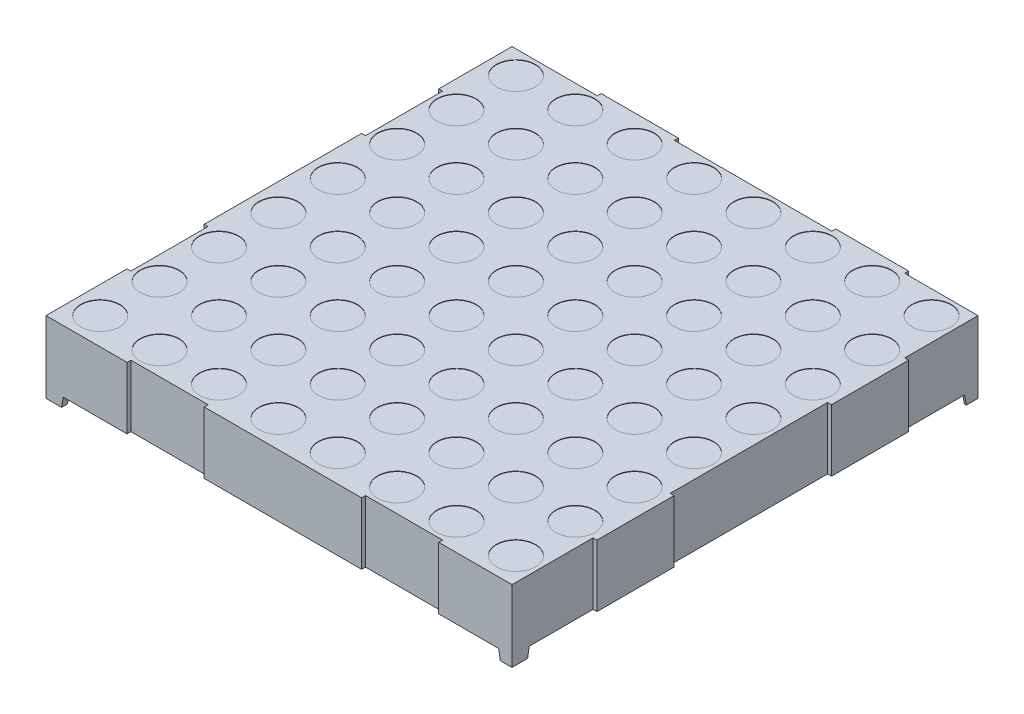
from build123d import *
from build123d.topology import SkipClean

# Parameters (mm, degrees)
EXTRUDE1_DEPTH     = 30.15
CUT_EXTRUDE1_DEPTH = 61.3
SKETCH2_R          = 2.5
CUT_EXTRUDE2_DEPTH = 0.05
SKETCH4_R          = 0.25
EXTRUDE2_DEPTH     = 1.25
SKETCH4_3_R        = 0.25
EXTRUDE3_DEPTH     = 4
SKETCH4_4_W        = 1.470408726
SKETCH4_4_H        = 1.470408726
CUT_EXTRUDE3_DEPTH = 1.25
SKETCH2_4_W        = 0.5
SKETCH2_4_H        = 9.9
SKETCH2_4_H_2      = 10.4
SKETCH2_4_H_3      = 20.2
SKETCH2_4_W_2      = 10.94
SKETCH2_4_H_4      = 0.5
SKETCH2_4_W_3      = 20.2
SKETCH2_4_W_4      = 9.4
SKETCH2_4_W_5      = 9.9
CUT_EXTRUDE5_DEPTH = 14.2
SKETCH5_W          = 0.026582279
SKETCH5_H          = 0.025316455
CUT_EXTRUDE6_DEPTH = 0.01


with BuildPart() as part:
    # Sketch1 → Extrude1 (new body, symmetric)
    with BuildSketch(Plane(origin=(0, 0, 0), x_dir=(0, 0, -1), z_dir=(1, 0, 0))):
        Polygon((30.15, 4.6), (-30.15, 4.6), (21.957065217, -3.35), (27.929591274, -3.35), (28.094707932, -4.286423101), (30.15, -4.6), align=None)
        Polygon((21.957065217, -3.35), (-30.15, 4.6), (-30.15, -4.6), (-28.15, -4.6), (-27.929591274, -3.35), align=None)
        Polygon((30.15, -4.6), (28.094707932, -4.286423101), (28.15, -4.6), align=None)
    extrude(amount=EXTRUDE1_DEPTH, both=True)

    # Sketch3 → Cut-Extrude1 (cut, through all)
    with BuildSketch(Plane.XY.offset(30.15)):
        Polygon((-27.929591274, -3.35), (-28.15, -4.6), (28.15, -4.6), (27.929591274, -3.35), align=None)
    extrude(amount=-CUT_EXTRUDE1_DEPTH, mode=Mode.SUBTRACT)

    # Sketch2 → Cut-Extrude2 (cut)
    with BuildSketch(Plane(origin=(0, 4.6, 0), x_dir=(-1, 0, 0), z_dir=(0, 1, 0))):
        with Locations(Location((11.43, 19.05, 0), (0, 0, 270))):  # turned: the seam where the file's is
            Circle(SKETCH2_R)
        with Locations(Location((11.43, -11.43, 0), (0, 0, 270))):  # turned: the seam where the file's is
            Circle(SKETCH2_R)
        with Locations(Location((11.43, -3.81, 0), (0, 0, 270))):  # turned: the seam where the file's is
            Circle(SKETCH2_R)
        with Locations(Location((11.43, -19.05, 0), (0, 0, 270))):  # turned: the seam where the file's is
            Circle(SKETCH2_R)
        with Locations(Location((11.43, 3.81, 0), (0, 0, 270))):  # turned: the seam where the file's is
            Circle(SKETCH2_R)
        with Locations(Location((11.43, 26.67, 0), (0, 0, 270))):  # turned: the seam where the file's is
            Circle(SKETCH2_R)
        with Locations(Location((11.43, 11.43, 0), (0, 0, 270))):  # turned: the seam where the file's is
            Circle(SKETCH2_R)
        with Locations(Location((3.81, -3.81, 0), (0, 0, 270))):  # turned: the seam where the file's is
            Circle(SKETCH2_R)
        with Locations(Location((3.81, 3.81, 0), (0, 0, 270))):  # turned: the seam where the file's is
            Circle(SKETCH2_R)
        with Locations(Location((3.81, 19.05, 0), (0, 0, 270))):  # turned: the seam where the file's is
            Circle(SKETCH2_R)
        with Locations(Location((3.81, 26.67, 0), (0, 0, 270))):  # turned: the seam where the file's is
            Circle(SKETCH2_R)
        with Locations(Location((3.81, -11.43, 0), (0, 0, 270))):  # turned: the seam where the file's is
            Circle(SKETCH2_R)
        with Locations(Location((3.81, -19.05, 0), (0, 0, 270))):  # turned: the seam where the file's is
            Circle(SKETCH2_R)
        with Locations(Location((3.81, 11.43, 0), (0, 0, 270))):  # turned: the seam where the file's is
            Circle(SKETCH2_R)
        with Locations(Location((-3.81, -3.81, 0), (0, 0, 270))):  # turned: the seam where the file's is
            Circle(SKETCH2_R)
        with Locations(Location((-3.81, 3.81, 0), (0, 0, 270))):  # turned: the seam where the file's is
            Circle(SKETCH2_R)
        with Locations(Location((-3.81, 19.05, 0), (0, 0, 270))):  # turned: the seam where the file's is
            Circle(SKETCH2_R)
        with Locations(Location((-3.81, 26.67, 0), (0, 0, 270))):  # turned: the seam where the file's is
            Circle(SKETCH2_R)
        with Locations(Location((-3.81, -11.43, 0), (0, 0, 270))):  # turned: the seam where the file's is
            Circle(SKETCH2_R)
        with Locations(Location((-3.81, -19.05, 0), (0, 0, 270))):  # turned: the seam where the file's is
            Circle(SKETCH2_R)
        with Locations(Location((-3.81, 11.43, 0), (0, 0, 270))):  # turned: the seam where the file's is
            Circle(SKETCH2_R)
        with Locations(Location((19.05, -3.81, 0), (0, 0, 270))):  # turned: the seam where the file's is
            Circle(SKETCH2_R)
        with Locations(Location((19.05, 3.81, 0), (0, 0, 270))):  # turned: the seam where the file's is
            Circle(SKETCH2_R)
        with Locations(Location((19.05, 19.05, 0), (0, 0, 270))):  # turned: the seam where the file's is
            Circle(SKETCH2_R)
        with Locations(Location((19.05, 26.67, 0), (0, 0, 270))):  # turned: the seam where the file's is
            Circle(SKETCH2_R)
        with Locations(Location((19.05, -11.43, 0), (0, 0, 270))):  # turned: the seam where the file's is
            Circle(SKETCH2_R)
        with Locations(Location((19.05, -19.05, 0), (0, 0, 270))):  # turned: the seam where the file's is
            Circle(SKETCH2_R)
        with Locations(Location((19.05, 11.43, 0), (0, 0, 270))):  # turned: the seam where the file's is
            Circle(SKETCH2_R)
        with Locations(Location((26.67, -3.81, 0), (0, 0, 270))):  # turned: the seam where the file's is
            Circle(SKETCH2_R)
        with Locations(Location((26.67, 3.81, 0), (0, 0, 270))):  # turned: the seam where the file's is
            Circle(SKETCH2_R)
        with Locations(Location((26.67, 19.05, 0), (0, 0, 270))):  # turned: the seam where the file's is
            Circle(SKETCH2_R)
        with Locations(Location((26.67, 26.67, 0), (0, 0, 270))):  # turned: the seam where the file's is
            Circle(SKETCH2_R)
        with Locations(Location((26.67, -11.43, 0), (0, 0, 270))):  # turned: the seam where the file's is
            Circle(SKETCH2_R)
        with Locations(Location((26.67, -19.05, 0), (0, 0, 270))):  # turned: the seam where the file's is
            Circle(SKETCH2_R)
        with Locations(Location((26.67, 11.43, 0), (0, 0, 270))):  # turned: the seam where the file's is
            Circle(SKETCH2_R)
        with Locations(Location((-11.43, -26.67, 0), (0, 0, 270))):  # turned: the seam where the file's is
            Circle(SKETCH2_R)
        with Locations(Location((-3.81, -26.67, 0), (0, 0, 270))):  # turned: the seam where the file's is
            Circle(SKETCH2_R)
        with Locations(Location((-19.05, -26.67, 0), (0, 0, 270))):  # turned: the seam where the file's is
            Circle(SKETCH2_R)
        with Locations(Location((-19.05, 11.43, 0), (0, 0, 270))):  # turned: the seam where the file's is
            Circle(SKETCH2_R)
        with Locations(Location((-19.05, -19.05, 0), (0, 0, 270))):  # turned: the seam where the file's is
            Circle(SKETCH2_R)
        with Locations(Location((-19.05, -11.43, 0), (0, 0, 270))):  # turned: the seam where the file's is
            Circle(SKETCH2_R)
        with Locations(Location((-19.05, 26.67, 0), (0, 0, 270))):  # turned: the seam where the file's is
            Circle(SKETCH2_R)
        with Locations(Location((-19.05, 19.05, 0), (0, 0, 270))):  # turned: the seam where the file's is
            Circle(SKETCH2_R)
        with Locations(Location((-19.05, 3.81, 0), (0, 0, 270))):  # turned: the seam where the file's is
            Circle(SKETCH2_R)
        with Locations(Location((-19.05, -3.81, 0), (0, 0, 270))):  # turned: the seam where the file's is
            Circle(SKETCH2_R)
        with Locations(Location((-11.43, 11.43, 0), (0, 0, 270))):  # turned: the seam where the file's is
            Circle(SKETCH2_R)
        with Locations(Location((-11.43, 26.67, 0), (0, 0, 270))):  # turned: the seam where the file's is
            Circle(SKETCH2_R)
        with Locations(Location((-11.43, 3.81, 0), (0, 0, 270))):  # turned: the seam where the file's is
            Circle(SKETCH2_R)
        with Locations(Location((-11.43, -19.05, 0), (0, 0, 270))):  # turned: the seam where the file's is
            Circle(SKETCH2_R)
        with Locations(Location((-11.43, -3.81, 0), (0, 0, 270))):  # turned: the seam where the file's is
            Circle(SKETCH2_R)
        with Locations(Location((-11.43, -11.43, 0), (0, 0, 270))):  # turned: the seam where the file's is
            Circle(SKETCH2_R)
        with Locations(Location((-11.43, 19.05, 0), (0, 0, 270))):  # turned: the seam where the file's is
            Circle(SKETCH2_R)
        with Locations(Location((26.67, -26.67, 0), (0, 0, 270))):  # turned: the seam where the file's is
            Circle(SKETCH2_R)
        with Locations(Location((19.05, -26.67, 0), (0, 0, 270))):  # turned: the seam where the file's is
            Circle(SKETCH2_R)
        with Locations(Location((3.81, -26.67, 0), (0, 0, 270))):  # turned: the seam where the file's is
            Circle(SKETCH2_R)
        with Locations(Location((11.43, -26.67, 0), (0, 0, 270))):  # turned: the seam where the file's is
            Circle(SKETCH2_R)
        with Locations(Location((-26.67, -26.67, 0), (0, 0, 270))):  # turned: the seam where the file's is
            Circle(SKETCH2_R)
        with Locations(Location((-26.67, 11.43, 0), (0, 0, 270))):  # turned: the seam where the file's is
            Circle(SKETCH2_R)
        with Locations(Location((-26.67, -19.05, 0), (0, 0, 270))):  # turned: the seam where the file's is
            Circle(SKETCH2_R)
        with Locations(Location((-26.67, -11.43, 0), (0, 0, 270))):  # turned: the seam where the file's is
            Circle(SKETCH2_R)
        with Locations(Location((-26.67, 26.67, 0), (0, 0, 270))):  # turned: the seam where the file's is
            Circle(SKETCH2_R)
        with Locations(Location((-26.67, 19.05, 0), (0, 0, 270))):  # turned: the seam where the file's is
            Circle(SKETCH2_R)
        with Locations(Location((-26.67, 3.81, 0), (0, 0, 270))):  # turned: the seam where the file's is
            Circle(SKETCH2_R)
        with Locations(Location((-26.67, -3.81, 0), (0, 0, 270))):  # turned: the seam where the file's is
            Circle(SKETCH2_R)
    extrude(amount=-CUT_EXTRUDE2_DEPTH, mode=Mode.SUBTRACT)

    # Sketch4 → Extrude2 (add)
    with BuildSketch(Plane.XZ.offset(4.6)):
        with Locations((-8.89, 22.86)):
            Circle(SKETCH4_R)
        with Locations(Location((-6.35, 22.86, 0), (0, 0, 270))):  # turned: the seam where the file's is
            Circle(SKETCH4_R)
        with Locations(Location((-3.81, 22.86, 0), (0, 0, 270))):  # turned: the seam where the file's is
            Circle(SKETCH4_R)
        with Locations(Location((6.35, 22.86, 0), (0, 0, 270))):  # turned: the seam where the file's is
            Circle(SKETCH4_R)
        with Locations(Location((-1.27, 22.86, 0), (0, 0, 270))):  # turned: the seam where the file's is
            Circle(SKETCH4_R)
        with Locations(Location((1.27, 22.86, 0), (0, 0, 270))):  # turned: the seam where the file's is
            Circle(SKETCH4_R)
        with Locations(Location((3.81, 22.86, 0), (0, 0, 270))):  # turned: the seam where the file's is
            Circle(SKETCH4_R)
        with Locations(Location((3.81, -22.86, 0), (0, 0, 270))):  # turned: the seam where the file's is
            Circle(SKETCH4_R)
        with Locations(Location((1.27, -22.86, 0), (0, 0, 270))):  # turned: the seam where the file's is
            Circle(SKETCH4_R)
        with Locations(Location((-1.27, -22.86, 0), (0, 0, 270))):  # turned: the seam where the file's is
            Circle(SKETCH4_R)
        with Locations(Location((6.35, -22.86, 0), (0, 0, 270))):  # turned: the seam where the file's is
            Circle(SKETCH4_R)
        with Locations(Location((-3.81, -22.86, 0), (0, 0, 270))):  # turned: the seam where the file's is
            Circle(SKETCH4_R)
        with Locations(Location((-6.35, -22.86, 0), (0, 0, 270))):  # turned: the seam where the file's is
            Circle(SKETCH4_R)
        with Locations(Location((-8.89, -22.86, 0), (0, 0, 270))):  # turned: the seam where the file's is
            Circle(SKETCH4_R)
        with Locations(Location((8.89, 22.86, 0), (0, 0, 270))):  # turned: the seam where the file's is
            Circle(SKETCH4_R)
        with Locations(Location((8.89, -22.86, 0), (0, 0, 270))):  # turned: the seam where the file's is
            Circle(SKETCH4_R)
    extrude(amount=-EXTRUDE2_DEPTH)

    # Sketch4_3 → Extrude3 (add)
    with SkipClean():  # keep this step's faces unmerged: merging them makes the solid invalid here
        with BuildSketch(Plane.XZ.offset(4.6)):
            with Locations((-8.89, 22.86)):
                Circle(SKETCH4_3_R)
            with Locations((-6.35, 22.86)):
                Circle(SKETCH4_3_R)
            with Locations((-3.81, 22.86)):
                Circle(SKETCH4_3_R)
            with Locations((6.35, 22.86)):
                Circle(SKETCH4_3_R)
            with Locations((-1.27, 22.86)):
                Circle(SKETCH4_3_R)
            with Locations((1.27, 22.86)):
                Circle(SKETCH4_3_R)
            with Locations(Location((3.81, 22.86, 0), (0, 0, 270))):  # turned: the seam where the file's is
                Circle(SKETCH4_3_R)
            with Locations(Location((3.81, -22.86, 0), (0, 0, 180))):  # turned: the seam where the file's is
                Circle(SKETCH4_3_R)
            with Locations(Location((1.27, -22.86, 0), (0, 0, 180))):  # turned: the seam where the file's is
                Circle(SKETCH4_3_R)
            with Locations(Location((-1.27, -22.86, 0), (0, 0, 180))):  # turned: the seam where the file's is
                Circle(SKETCH4_3_R)
            with Locations(Location((6.35, -22.86, 0), (0, 0, 180))):  # turned: the seam where the file's is
                Circle(SKETCH4_3_R)
            with Locations(Location((-3.81, -22.86, 0), (0, 0, 270))):  # turned: the seam where the file's is
                Circle(SKETCH4_3_R)
            with Locations(Location((-6.35, -22.86, 0), (0, 0, 270))):  # turned: the seam where the file's is
                Circle(SKETCH4_3_R)
            with Locations(Location((-8.89, -22.86, 0), (0, 0, 270))):  # turned: the seam where the file's is
                Circle(SKETCH4_3_R)
            with Locations(Location((8.89, 22.86, 0), (0, 0, 270))):  # turned: the seam where the file's is
                Circle(SKETCH4_3_R)
            with Locations(Location((8.89, -22.86, 0), (0, 0, 270))):  # turned: the seam where the file's is
                Circle(SKETCH4_3_R)
        extrude(amount=EXTRUDE3_DEPTH)

    # Sketch4_4 → Cut-Extrude3 (cut)
    with SkipClean():  # keep this step's faces unmerged: merging them makes the solid invalid here
        with BuildSketch(Plane.XZ.offset(4.6)):
            with Locations((-28.664795637, 28.664795637)):
                Rectangle(SKETCH4_4_W, SKETCH4_4_H)
            with Locations((28.664795637, 28.664795637)):
                Rectangle(SKETCH4_4_W, SKETCH4_4_H)
            with Locations((28.664795637, -28.664795637)):
                Rectangle(SKETCH4_4_W, SKETCH4_4_H)
            with Locations((-28.664795637, -28.664795637)):
                Rectangle(SKETCH4_4_W, SKETCH4_4_H)
        extrude(amount=-CUT_EXTRUDE3_DEPTH, mode=Mode.SUBTRACT)

    # Sketch2_4 → Cut-Extrude5 (cut, through all)
    with SkipClean():  # keep this step's faces unmerged: merging them makes the solid invalid here
        with BuildSketch(Plane(origin=(0, 4.6, 0), x_dir=(-1, 0, 0), z_dir=(0, 1, 0))):
            with Locations((29.9, -15.3)):
                Rectangle(SKETCH2_4_W, SKETCH2_4_H)
            with Locations((29.9, 14.8)):
                Rectangle(SKETCH2_4_W, SKETCH2_4_H)
            with Locations((-29.9, 24.95)):
                Rectangle(SKETCH2_4_W, SKETCH2_4_H_2)
            with Locations((-29.9, -0.25)):
                Rectangle(SKETCH2_4_W, SKETCH2_4_H_3)
            Polygon((-30.15, -30.15), (-29.65, -30.15), (-29.65, -29.65), (-29.65, -20.25), (-30.15, -20.25), align=None)
            with Locations((24.68, -29.9)):
                Rectangle(SKETCH2_4_W_2, SKETCH2_4_H_4)
            with Locations((-0.79, -29.9)):
                Rectangle(SKETCH2_4_W_3, SKETCH2_4_H_4)
            with Locations((-24.95, -29.9)):
                Rectangle(SKETCH2_4_W_4, SKETCH2_4_H_4)
            with Locations((-15.3, 29.9)):
                Rectangle(SKETCH2_4_W_5, SKETCH2_4_H_4)
            with Locations((14.8, 29.9)):
                Rectangle(SKETCH2_4_W_5, SKETCH2_4_H_4)
        extrude(amount=-CUT_EXTRUDE5_DEPTH, mode=Mode.SUBTRACT)

    # Sketch5 → Cut-Extrude6 (cut)
    with SkipClean():  # keep this step's faces unmerged: merging them makes the solid invalid here
        with BuildSketch(Plane.XZ.offset(3.35)):
            Polygon((-19.118836488, 0.807594731), (-19.193520033, 0.831052009), (-19.193520033, 0.855794889), (-19.143183798, 0.872211028), (-19.193520033, 0.887737136), (-19.193520033, 0.91346894), (-19.118836488, 0.936708655), (-19.118836488, 0.911530649), (-19.170319874, 0.898536187), (-19.118836488, 0.882120047), (-19.118836488, 0.860620839), (-19.170319874, 0.844303592), (-19.118836488, 0.831487136), align=None)
            Polygon((-19.118836488, 0.673417516), (-19.193520033, 0.696874794), (-19.193520033, 0.721617674), (-19.143183798, 0.738033813), (-19.193520033, 0.753559921), (-19.193520033, 0.779291725), (-19.118836488, 0.80253144), (-19.118836488, 0.777353434), (-19.170319874, 0.764358972), (-19.118836488, 0.747942832), (-19.118836488, 0.726443623), (-19.170319874, 0.710126377), (-19.118836488, 0.697309921), align=None)
            Polygon((-19.118836488, 0.539240301), (-19.193520033, 0.562697579), (-19.193520033, 0.587440459), (-19.143183798, 0.603856598), (-19.193520033, 0.619382706), (-19.193520033, 0.645114509), (-19.118836488, 0.668354225), (-19.118836488, 0.643176218), (-19.170319874, 0.630181756), (-19.118836488, 0.613765617), (-19.118836488, 0.592266408), (-19.170319874, 0.575949161), (-19.118836488, 0.563132706), align=None)
            with Locations((-19.180228894, 0.5113922)):
                Rectangle(SKETCH5_W, SKETCH5_H)
            with BuildLine():
                add(Edge.make_bspline(
                    [(-19.162349147, 0.394936503), (-19.16357128, 0.394973001), (-19.165971143, 0.395044672), (-19.169478831, 0.395654258), (-19.172803134, 0.396648225), (-19.17596728, 0.398020564), (-19.178936769, 0.399814021), (-19.18173966, 0.401997292), (-19.184344205, 0.404586175), (-19.186780579, 0.407532979), (-19.18896269, 0.410829921), (-19.190868724, 0.414427636), (-19.192463395, 0.418307663), (-19.19380246, 0.422455874), (-19.194790894, 0.42690242), (-19.195514881, 0.431619919), (-19.195988199, 0.436613346), (-19.196030167, 0.440036923), (-19.196051678, 0.441791725)],
                    knots=[0, 0, 0, 0, 0.907312236, 1.78165839, 2.635367075, 3.479697475, 4.336364812, 5.205276731, 6.11257575, 7.058770404, 8.040786331, 9.044147278, 10.078219212, 11.153049307, 12.278104542, 13.457648573, 14.696882856, 16, 16, 16, 16], degree=3))
                add(Edge.make_bspline(
                    [(-19.196051678, 0.441791725), (-19.196027607, 0.44380998), (-19.195980982, 0.447719162), (-19.195552383, 0.453382687), (-19.194906243, 0.458650725), (-19.193939701, 0.463546439), (-19.192738936, 0.468151039), (-19.191447645, 0.472584306), (-19.189983229, 0.476865618), (-19.188883071, 0.479638708), (-19.188338071, 0.481012453)],
                    knots=[0, 0, 0, 0, 1.203215828, 2.33052265, 3.384689099, 4.366106119, 5.303329643, 6.221311756, 7.118865988, 8, 8, 8, 8], degree=3))
                Line((-19.188338071, 0.481012453), (-19.164406109, 0.481012453))
                Line((-19.164406109, 0.481012453), (-19.164406109, 0.478164351))
                add(Edge.make_bspline(
                    [(-19.164406109, 0.478164351), (-19.165487564, 0.476799037), (-19.167644125, 0.474076425), (-19.17040673, 0.469643191), (-19.172808893, 0.464995546), (-19.174782894, 0.460150075), (-19.176369219, 0.45525323), (-19.177462746, 0.450377853), (-19.178210095, 0.445612265), (-19.178290601, 0.442453696), (-19.178330159, 0.440901693)],
                    knots=[0, 0, 0, 0, 1.030622468, 2.055194264, 3.087043286, 4.125157485, 5.149848264, 6.130935704, 7.081611712, 8, 8, 8, 8], degree=3))
                add(Edge.make_bspline(
                    [(-19.178330159, 0.440901693), (-19.178329265, 0.440472914), (-19.17832735, 0.439554933), (-19.178198507, 0.438086896), (-19.178105343, 0.436428296), (-19.177896126, 0.43464943), (-19.177677542, 0.432858613), (-19.177297222, 0.431203953), (-19.176935384, 0.429700314), (-19.176567206, 0.428793832), (-19.176391868, 0.428362136)],
                    knots=[0, 0, 0, 0, 0.806378557, 1.726393851, 2.771014456, 3.931269413, 5.096090628, 6.161710732, 7.124547685, 8, 8, 8, 8], degree=3))
                add(Edge.make_bspline(
                    [(-19.176391868, 0.428362136), (-19.176164044, 0.427882349), (-19.175716322, 0.426939466), (-19.174898715, 0.425644547), (-19.174027414, 0.424461874), (-19.173061995, 0.423400414), (-19.171884086, 0.422550146), (-19.17048323, 0.421921945), (-19.16883293, 0.421578851), (-19.167657919, 0.421539558), (-19.167036647, 0.421518782)],
                    knots=[0, 0, 0, 0, 1.024407818, 2.013179384, 2.949802342, 3.859052226, 4.77034807, 5.732977883, 6.801339628, 8, 8, 8, 8], degree=3))
                add(Edge.make_bspline(
                    [(-19.167036647, 0.421518782), (-19.16649075, 0.421550223), (-19.165417358, 0.421612047), (-19.163889362, 0.422193838), (-19.162467485, 0.423076737), (-19.161206769, 0.424363759), (-19.160049331, 0.425957836), (-19.159079034, 0.427913572), (-19.158198961, 0.430166552), (-19.157781692, 0.431811011), (-19.157562754, 0.432673845)],
                    knots=[0, 0, 0, 0, 0.825212765, 1.622611382, 2.449701629, 3.348069183, 4.336544339, 5.428209675, 6.6506027, 8, 8, 8, 8], degree=3))
                add(Edge.make_bspline(
                    [(-19.157562754, 0.432673845), (-19.157115014, 0.434642572), (-19.156197824, 0.43867548), (-19.155050717, 0.444823589), (-19.153784644, 0.450953817), (-19.152575102, 0.454912528), (-19.151985223, 0.456843149)],
                    knots=[0, 0, 0, 0, 0.976104583, 1.999535498, 3.024395274, 4, 4, 4, 4], degree=3))
                add(Edge.make_bspline(
                    [(-19.151985223, 0.456843149), (-19.15163223, 0.457881665), (-19.150945097, 0.459903233), (-19.149783472, 0.462794777), (-19.14851352, 0.46545589), (-19.147158388, 0.467896), (-19.14568439, 0.470095322), (-19.144151001, 0.472090512), (-19.142497164, 0.473834038), (-19.140765244, 0.475381721), (-19.138913241, 0.476705036), (-19.136969105, 0.477859786), (-19.134908639, 0.478835422), (-19.132747351, 0.479644305), (-19.130468482, 0.480261378), (-19.128091609, 0.480682634), (-19.125608248, 0.480981023), (-19.123913895, 0.481001833), (-19.123049305, 0.481012453)],
                    knots=[0, 0, 0, 0, 1.287286806, 2.505824366, 3.654938963, 4.74627059, 5.778586806, 6.75996495, 7.696030012, 8.595059759, 9.482019644, 10.363222407, 11.245851011, 12.154256429, 13.068444161, 14.012503255, 14.985824751, 16, 16, 16, 16], degree=3))
                add(Edge.make_bspline(
                    [(-19.123049305, 0.481012453), (-19.12189316, 0.480975151), (-19.119617888, 0.480901741), (-19.116288843, 0.480300312), (-19.113140107, 0.479273723), (-19.110136644, 0.477887659), (-19.107323558, 0.476059031), (-19.10464501, 0.473874237), (-19.102173419, 0.471250189), (-19.099873085, 0.468273068), (-19.097793687, 0.464985683), (-19.09596313, 0.4614467), (-19.094426479, 0.457677411), (-19.093152585, 0.453691864), (-19.092197914, 0.449473395), (-19.091478982, 0.445036162), (-19.091065801, 0.440362374), (-19.09101455, 0.437170952), (-19.090988387, 0.435541725)],
                    knots=[0, 0, 0, 0, 0.894990994, 1.761326291, 2.609044902, 3.454222546, 4.315366365, 5.200560057, 6.125081389, 7.100429509, 8.110379559, 9.133447974, 10.182136699, 11.259192205, 12.370181258, 13.528580438, 14.738335141, 16, 16, 16, 16], degree=3))
                add(Edge.make_bspline(
                    [(-19.090988387, 0.435541725), (-19.091010579, 0.433873038), (-19.091054924, 0.430538493), (-19.091432901, 0.42555705), (-19.09198813, 0.420596548), (-19.092829835, 0.415732718), (-19.093806252, 0.411042163), (-19.094902048, 0.406628927), (-19.096140012, 0.402549467), (-19.097094357, 0.399975802), (-19.097554843, 0.398733972)],
                    knots=[0, 0, 0, 0, 1.065403572, 2.129000689, 3.188532477, 4.251604565, 5.279552602, 6.247508681, 7.154397237, 8, 8, 8, 8], degree=3))
                Line((-19.097554843, 0.398733972), (-19.120102311, 0.398733972))
                Line((-19.120102311, 0.398733972), (-19.120102311, 0.401562294))
                add(Edge.make_bspline(
                    [(-19.120102311, 0.401562294), (-19.119301964, 0.402635199), (-19.117665235, 0.404829317), (-19.115581562, 0.408488954), (-19.113623697, 0.41244719), (-19.111939538, 0.41672602), (-19.110480056, 0.421185048), (-19.10946089, 0.425768007), (-19.108819081, 0.43039417), (-19.108746306, 0.433495881), (-19.108709906, 0.435047263)],
                    knots=[0, 0, 0, 0, 0.892283326, 1.824742884, 2.804416662, 3.836872171, 4.8899239, 5.931447339, 6.965372909, 8, 8, 8, 8], degree=3))
                add(Edge.make_bspline(
                    [(-19.108709906, 0.435047263), (-19.108731358, 0.43614293), (-19.108774261, 0.438334147), (-19.109164945, 0.441602355), (-19.109795839, 0.444844416), (-19.11061512, 0.446884939), (-19.111023988, 0.447903275)],
                    knots=[0, 0, 0, 0, 0.999146175, 1.998183711, 3.000980573, 4, 4, 4, 4], degree=3))
                add(Edge.make_bspline(
                    [(-19.111023988, 0.447903275), (-19.111225455, 0.448336779), (-19.111628254, 0.449203496), (-19.112400818, 0.450410141), (-19.113329629, 0.451514809), (-19.114381621, 0.452506887), (-19.115537995, 0.453375284), (-19.116812821, 0.453990636), (-19.118175736, 0.454366509), (-19.119110967, 0.454408667), (-19.119588071, 0.454430174)],
                    knots=[0, 0, 0, 0, 1.00524851, 2.009826503, 3.004679593, 4.035271301, 5.048246368, 6.034938417, 6.997532266, 8, 8, 8, 8], degree=3))
                add(Edge.make_bspline(
                    [(-19.119588071, 0.454430174), (-19.120226236, 0.454395736), (-19.121445712, 0.454329928), (-19.123161508, 0.453723343), (-19.124639941, 0.45273851), (-19.125634861, 0.451577905), (-19.1263323, 0.450460776), (-19.12684281, 0.449425116), (-19.127326169, 0.448215889), (-19.127823637, 0.446844641), (-19.128314825, 0.445308314), (-19.128790372, 0.443599757), (-19.129239667, 0.44171704), (-19.129525858, 0.440401165), (-19.129675096, 0.439714984)],
                    knots=[0, 0, 0, 0, 1.173816843, 2.243057204, 3.312297565, 4.415174738, 5.03266065, 5.73970059, 6.541434878, 7.433956553, 8.430083051, 9.515931566, 10.70464786, 12, 12, 12, 12], degree=3))
                add(Edge.make_bspline(
                    [(-19.129675096, 0.439714984), (-19.130051157, 0.437882195), (-19.130790035, 0.434281169), (-19.131893524, 0.428879985), (-19.133168493, 0.423377212), (-19.134317296, 0.419711885), (-19.134916393, 0.417800427)],
                    knots=[0, 0, 0, 0, 0.995744513, 1.956417928, 2.934277412, 4, 4, 4, 4], degree=3))
                add(Edge.make_bspline(
                    [(-19.134916393, 0.417800427), (-19.135235637, 0.416853873), (-19.13586013, 0.41500226), (-19.136946413, 0.412361629), (-19.138120395, 0.409914571), (-19.139361927, 0.407647538), (-19.140705893, 0.405573568), (-19.14212854, 0.403678886), (-19.143655449, 0.401995067), (-19.145268676, 0.400497502), (-19.146978777, 0.399178342), (-19.148817849, 0.398046044), (-19.150766651, 0.397073816), (-19.152852851, 0.396304211), (-19.155047439, 0.39568619), (-19.157378806, 0.395263093), (-19.159823183, 0.39496911), (-19.16149776, 0.394947493), (-19.162349147, 0.394936503)],
                    knots=[0, 0, 0, 0, 1.237467875, 2.420686895, 3.535046182, 4.599015201, 5.620884487, 6.594603852, 7.531477383, 8.433220087, 9.318759595, 10.202828513, 11.105163009, 12.01247538, 12.953896178, 13.926381251, 14.945733412, 16, 16, 16, 16], degree=3))
            make_face()
            with BuildLine():
                Line((-19.193520033, 0.30253144), (-19.193520033, 0.326582073))
                Line((-19.193520033, 0.326582073), (-19.185687754, 0.326582073))
                add(Edge.make_bspline(
                    [(-19.185687754, 0.326582073), (-19.186496312, 0.327675382), (-19.188055201, 0.329783265), (-19.190135419, 0.33295629), (-19.191910685, 0.335982381), (-19.193469905, 0.338895871), (-19.194645291, 0.341918074), (-19.195473357, 0.345149589), (-19.19597313, 0.348652413), (-19.196024914, 0.351079307), (-19.196051678, 0.352333655)],
                    knots=[0, 0, 0, 0, 1.150872466, 2.218865267, 3.209461834, 4.120482262, 5.012764827, 5.946708227, 6.938749913, 8, 8, 8, 8], degree=3))
                add(Edge.make_bspline(
                    [(-19.196051678, 0.352333655), (-19.196028959, 0.353350007), (-19.195984719, 0.355329137), (-19.195639841, 0.358206377), (-19.195102189, 0.360914005), (-19.194294599, 0.363429045), (-19.193328795, 0.365793034), (-19.192048837, 0.367930584), (-19.190618663, 0.369934186), (-19.188911618, 0.371715859), (-19.187013885, 0.37333148), (-19.184881424, 0.37471403), (-19.182548499, 0.375891741), (-19.179996645, 0.376832839), (-19.177238342, 0.377587928), (-19.174259094, 0.37811186), (-19.171071966, 0.378432453), (-19.168876836, 0.378464392), (-19.167748672, 0.378480807)],
                    knots=[0, 0, 0, 0, 1.109008058, 2.159558935, 3.158726032, 4.116861086, 5.039058877, 5.938775559, 6.82970133, 7.720510853, 8.624361809, 9.544451588, 10.487360536, 11.471068125, 12.508000841, 13.604731202, 14.768976642, 16, 16, 16, 16], degree=3))
                Line((-19.167748672, 0.378480807), (-19.118836488, 0.378480807))
                Line((-19.118836488, 0.378480807), (-19.118836488, 0.354430174))
                Line((-19.118836488, 0.354430174), (-19.156415602, 0.354430174))
                add(Edge.make_bspline(
                    [(-19.156415602, 0.354430174), (-19.157332073, 0.354428538), (-19.159086289, 0.354425408), (-19.161592095, 0.354343069), (-19.163860268, 0.354222168), (-19.165902297, 0.354083464), (-19.167749047, 0.353830447), (-19.169415208, 0.353452739), (-19.17093481, 0.352981913), (-19.171841512, 0.352517594), (-19.172277944, 0.352294098)],
                    knots=[0, 0, 0, 0, 1.361401701, 2.605856924, 3.723918663, 4.735739235, 5.645738665, 6.489217889, 7.27279937, 8, 8, 8, 8], degree=3))
                add(Edge.make_bspline(
                    [(-19.172277944, 0.352294098), (-19.172676659, 0.352064091), (-19.173460498, 0.351611918), (-19.174466676, 0.350691628), (-19.175310944, 0.349612885), (-19.175966973, 0.348335282), (-19.176465921, 0.346848733), (-19.176806158, 0.345120803), (-19.177021659, 0.343135441), (-19.177049568, 0.341726423), (-19.177064336, 0.340980807)],
                    knots=[0, 0, 0, 0, 0.849138082, 1.669332372, 2.503455908, 3.370611167, 4.311442699, 5.394692208, 6.621337967, 8, 8, 8, 8], degree=3))
                add(Edge.make_bspline(
                    [(-19.177064336, 0.340980807), (-19.177046979, 0.340439523), (-19.177011292, 0.339326606), (-19.176778846, 0.337615293), (-19.176422171, 0.335818716), (-19.175762316, 0.333304133), (-19.174576137, 0.330137506), (-19.173221729, 0.327778205), (-19.172535064, 0.326582073)],
                    knots=[0, 0, 0, 0, 0.638127216, 1.312033637, 2.033062677, 2.79661882, 4.375931797, 6, 6, 6, 6], degree=3))
                Line((-19.172535064, 0.326582073), (-19.118836488, 0.326582073))
                Line((-19.118836488, 0.326582073), (-19.118836488, 0.30253144))
                Line((-19.118836488, 0.30253144), (-19.193520033, 0.30253144))
            make_face()
            with BuildLine():
                Line((-19.193520033, 0.205063085), (-19.193520033, 0.229113718))
                Line((-19.193520033, 0.229113718), (-19.155940919, 0.229113718))
                add(Edge.make_bspline(
                    [(-19.155940919, 0.229113718), (-19.154410876, 0.229138233), (-19.151359851, 0.229187116), (-19.14759744, 0.22946924), (-19.144755116, 0.229847762), (-19.142917235, 0.230217418), (-19.141369095, 0.230649118), (-19.140483336, 0.231061398), (-19.140078577, 0.231249794)],
                    knots=[0, 0, 0, 0, 1.709124929, 3.408128882, 4.211124727, 4.91016634, 5.501986363, 6, 6, 6, 6], degree=3))
                add(Edge.make_bspline(
                    [(-19.140078577, 0.231249794), (-19.139680524, 0.231494257), (-19.138900084, 0.231973561), (-19.137887071, 0.232910885), (-19.13705823, 0.234004771), (-19.136376679, 0.23527554), (-19.135906098, 0.236766737), (-19.135512868, 0.238483478), (-19.13534596, 0.240470096), (-19.1353108, 0.241877366), (-19.135292185, 0.242622421)],
                    knots=[0, 0, 0, 0, 0.86006424, 1.686277094, 2.52783008, 3.38194165, 4.331801563, 5.402842185, 6.624978739, 8, 8, 8, 8], degree=3))
                add(Edge.make_bspline(
                    [(-19.135292185, 0.242622421), (-19.135348922, 0.243754243), (-19.135464775, 0.246065337), (-19.136176283, 0.24892753), (-19.136995242, 0.251258134), (-19.137754073, 0.253110659), (-19.138725514, 0.25501929), (-19.139447337, 0.256298702), (-19.139821457, 0.25696182)],
                    knots=[0, 0, 0, 0, 1.338371478, 2.732853438, 3.468019217, 4.261884641, 5.099136535, 6, 6, 6, 6], degree=3))
                Line((-19.139821457, 0.25696182), (-19.193520033, 0.25696182))
                Line((-19.193520033, 0.25696182), (-19.193520033, 0.281012453))
                Line((-19.193520033, 0.281012453), (-19.118836488, 0.281012453))
                Line((-19.118836488, 0.281012453), (-19.118836488, 0.25696182))
                Line((-19.118836488, 0.25696182), (-19.126668767, 0.25696182))
                add(Edge.make_bspline(
                    [(-19.126668767, 0.25696182), (-19.125862615, 0.255904413), (-19.124293393, 0.253846108), (-19.122252973, 0.250666871), (-19.120454203, 0.247582973), (-19.118941387, 0.244529963), (-19.117734612, 0.241415008), (-19.116923623, 0.23815225), (-19.11637982, 0.234735843), (-19.116330126, 0.232399128), (-19.116304843, 0.231210237)],
                    knots=[0, 0, 0, 0, 1.126119141, 2.192057864, 3.198061997, 4.149848529, 5.076251285, 6.021887753, 6.99356175, 8, 8, 8, 8], degree=3))
                add(Edge.make_bspline(
                    [(-19.116304843, 0.231210237), (-19.116330232, 0.230213966), (-19.116379796, 0.228269067), (-19.116689505, 0.225434306), (-19.117240169, 0.222762885), (-19.118037999, 0.220270612), (-19.119023611, 0.217927992), (-19.120255126, 0.215766047), (-19.121713549, 0.213773976), (-19.123374552, 0.211945576), (-19.125264278, 0.210314758), (-19.127381542, 0.208897721), (-19.129724639, 0.20771774), (-19.132284948, 0.206747028), (-19.135050057, 0.205972604), (-19.138046022, 0.205457473), (-19.141250201, 0.20510369), (-19.143466244, 0.205076891), (-19.144607849, 0.205063085)],
                    knots=[0, 0, 0, 0, 1.08848837, 2.124922927, 3.110950502, 4.063144162, 4.979605775, 5.882838355, 6.774625441, 7.671951181, 8.57587277, 9.494821853, 10.448322275, 11.435533005, 12.482327682, 13.580118324, 14.753386918, 16, 16, 16, 16], degree=3))
                Line((-19.144607849, 0.205063085), (-19.193520033, 0.205063085))
            make_face()
            Polygon((-19.193520033, 0.110126377), (-19.193520033, 0.182278275), (-19.093520033, 0.182278275), (-19.093520033, 0.15696182), (-19.174532691, 0.15696182), (-19.174532691, 0.110126377), align=None)
            Polygon((-19.193520033, 0.022784604), (-19.193520033, 0.094936503), (-19.093520033, 0.094936503), (-19.093520033, 0.022784604), (-19.112507374, 0.022784604), (-19.112507374, 0.069620047), (-19.130228893, 0.069620047), (-19.130228893, 0.026582073), (-19.149216235, 0.026582073), (-19.149216235, 0.069620047), (-19.174532691, 0.069620047), (-19.174532691, 0.022784604), align=None)
            with BuildLine():
                add(Edge.make_bspline(
                    [(-19.143618925, -0.093671092), (-19.144766614, -0.093651776), (-19.1470395, -0.093613524), (-19.150404307, -0.093318333), (-19.153669982, -0.092792308), (-19.156854231, -0.092113126), (-19.159933158, -0.09119062), (-19.162940735, -0.090108907), (-19.165846229, -0.088799261), (-19.168647663, -0.087294408), (-19.171319766, -0.085644936), (-19.173839975, -0.083870187), (-19.176223193, -0.082024408), (-19.178418087, -0.080035095), (-19.180460106, -0.077955913), (-19.182350921, -0.075780385), (-19.184054351, -0.073475321), (-19.185077236, -0.071868158), (-19.185588862, -0.071064288)],
                    knots=[0, 0, 0, 0, 1.105570398, 2.18947457, 3.250358341, 4.290584537, 5.323553275, 6.344225964, 7.367641686, 8.3905646, 9.405808457, 10.390761353, 11.358902336, 12.307789878, 13.241960776, 14.165076779, 15.082208636, 16, 16, 16, 16], degree=3))
                add(Edge.make_bspline(
                    [(-19.185588862, -0.071064288), (-19.186301001, -0.06982506), (-19.187728914, -0.06734028), (-19.189397504, -0.063356445), (-19.19080162, -0.059230963), (-19.191856045, -0.054880577), (-19.192583089, -0.050233567), (-19.193143895, -0.045232158), (-19.193445655, -0.039824568), (-19.193494675, -0.036089674), (-19.193520033, -0.034157642)],
                    knots=[0, 0, 0, 0, 0.896288622, 1.797150563, 2.705281913, 3.629615989, 4.602417572, 5.655716007, 6.787320449, 8, 8, 8, 8], degree=3))
                Line((-19.193520033, -0.034157642), (-19.193520033, 0.001265617))
                Line((-19.193520033, 0.001265617), (-19.093520033, 0.001265617))
                Line((-19.093520033, 0.001265617), (-19.093520033, -0.035166345))
                add(Edge.make_bspline(
                    [(-19.093520033, -0.035166345), (-19.093536644, -0.037145077), (-19.093568684, -0.040961805), (-19.093986275, -0.046478644), (-19.094583099, -0.051583852), (-19.09550797, -0.0562692), (-19.096623315, -0.060569205), (-19.097982443, -0.064494681), (-19.099481151, -0.068106455), (-19.100754844, -0.070285296), (-19.10137209, -0.071341187)],
                    knots=[0, 0, 0, 0, 1.267175336, 2.444223962, 3.542125549, 4.557526608, 5.500936977, 6.385043188, 7.217374394, 8, 8, 8, 8], degree=3))
                add(Edge.make_bspline(
                    [(-19.10137209, -0.071341187), (-19.10190863, -0.07219214), (-19.102975544, -0.073884265), (-19.104757396, -0.076285479), (-19.106713473, -0.078514907), (-19.108765292, -0.080643409), (-19.110968179, -0.082623227), (-19.113306886, -0.084466427), (-19.11578498, -0.086170244), (-19.118394449, -0.087728207), (-19.121124501, -0.089149022), (-19.12399756, -0.090338328), (-19.12697609, -0.091387677), (-19.130085052, -0.092193213), (-19.133292888, -0.092891127), (-19.136634233, -0.093325862), (-19.140086721, -0.093612473), (-19.14243161, -0.093651388), (-19.143618925, -0.093671092)],
                    knots=[0, 0, 0, 0, 0.964065863, 1.917049184, 2.86229036, 3.805247319, 4.749389377, 5.698846072, 6.657678277, 7.629829384, 8.610569287, 9.604676042, 10.607940105, 11.6349849, 12.681042988, 13.752616828, 14.862056989, 16, 16, 16, 16], degree=3))
            make_face()
            with BuildLine():
                add(Edge.make_bspline(
                    [(-19.143460697, -0.067088813), (-19.142655937, -0.067078573), (-19.141077353, -0.067058485), (-19.138761839, -0.066866918), (-19.136532189, -0.066607861), (-19.134397496, -0.066176807), (-19.132337926, -0.06567716), (-19.130380432, -0.065035011), (-19.128500859, -0.064310614), (-19.12672337, -0.063428977), (-19.125014987, -0.06245534), (-19.123429472, -0.061307846), (-19.121916586, -0.060059509), (-19.120488601, -0.058681222), (-19.119182705, -0.057138282), (-19.117952629, -0.055478179), (-19.116824303, -0.053677821), (-19.116164254, -0.052404833), (-19.115830159, -0.051760491)],
                    knots=[0, 0, 0, 0, 1.152093354, 2.259898929, 3.325467225, 4.364140538, 5.376172865, 6.358396836, 7.312077728, 8.257828931, 9.196960457, 10.124297759, 11.056236784, 12.004246951, 12.961658638, 13.947279359, 14.960983522, 16, 16, 16, 16], degree=3))
                add(Edge.make_bspline(
                    [(-19.115830159, -0.051760491), (-19.115523447, -0.051085593), (-19.114915523, -0.049747899), (-19.11418433, -0.047677076), (-19.113611495, -0.045587692), (-19.113180636, -0.043386093), (-19.112858706, -0.040916333), (-19.112661447, -0.037990751), (-19.112519278, -0.034534842), (-19.112511526, -0.032048127), (-19.112507374, -0.030716187)],
                    knots=[0, 0, 0, 0, 0.826967603, 1.639107464, 2.447640171, 3.242670507, 4.14065217, 5.225198036, 6.513753944, 8, 8, 8, 8], degree=3))
                Line((-19.112507374, -0.030716187), (-19.112507374, -0.024050839))
                Line((-19.112507374, -0.024050839), (-19.174532691, -0.024050839))
                Line((-19.174532691, -0.024050839), (-19.174532691, -0.030716187))
                add(Edge.make_bspline(
                    [(-19.174532691, -0.030716187), (-19.174527941, -0.031474394), (-19.174518772, -0.032938159), (-19.174475709, -0.035054403), (-19.174428822, -0.037020199), (-19.17431236, -0.03882507), (-19.174239714, -0.040483754), (-19.174061335, -0.041970535), (-19.173919155, -0.043313025), (-19.173651432, -0.044880621), (-19.173235249, -0.046733787), (-19.17255707, -0.048895048), (-19.171706674, -0.051035582), (-19.171021707, -0.052424155), (-19.170675887, -0.053125206)],
                    knots=[0, 0, 0, 0, 1.186793418, 2.291178421, 3.313283093, 4.264083014, 5.122158624, 5.910777728, 6.607099052, 7.234812932, 8.398911528, 9.577194775, 10.776795607, 12, 12, 12, 12], degree=3))
                add(Edge.make_bspline(
                    [(-19.170675887, -0.053125206), (-19.170334371, -0.053710322), (-19.169660856, -0.054864247), (-19.168526783, -0.056487752), (-19.167319058, -0.05799547), (-19.166030607, -0.059391482), (-19.164642365, -0.060654781), (-19.163175824, -0.0618068), (-19.161627845, -0.062837249), (-19.159434328, -0.064072638), (-19.156403391, -0.065295884), (-19.152436005, -0.066335427), (-19.148076241, -0.066972298), (-19.145038624, -0.06704898), (-19.143460697, -0.067088813)],
                    knots=[0, 0, 0, 0, 0.755160452, 1.489275589, 2.205657296, 2.907868421, 3.605098304, 4.296256403, 4.985378686, 5.676536785, 7.100390329, 8.614249252, 10.241231541, 12, 12, 12, 12], degree=3))
            make_face(mode=Mode.SUBTRACT)
            with Locations((-19.180228894, -0.125316662)):
                Rectangle(SKETCH5_W, SKETCH5_H)
            with BuildLine():
                add(Edge.make_bspline(
                    [(-19.196051678, -0.199960649), (-19.196029867, -0.198370536), (-19.195987055, -0.195249399), (-19.195510138, -0.190678058), (-19.194792443, -0.186312885), (-19.193771536, -0.182166577), (-19.19242404, -0.178252786), (-19.190771105, -0.174589148), (-19.18878592, -0.171182291), (-19.187206711, -0.169123644), (-19.186419558, -0.168097516)],
                    knots=[0, 0, 0, 0, 1.123670284, 2.205584497, 3.245308791, 4.249063313, 5.220352711, 6.167273909, 7.086481357, 8, 8, 8, 8], degree=3))
                add(Edge.make_bspline(
                    [(-19.186419558, -0.168097516), (-19.185564784, -0.167145768), (-19.183858541, -0.165245954), (-19.180887114, -0.16278002), (-19.17760407, -0.160656935), (-19.174001847, -0.158871382), (-19.170085119, -0.157440459), (-19.165840456, -0.156417325), (-19.161279676, -0.155798079), (-19.158131742, -0.155730914), (-19.156514495, -0.155696408)],
                    knots=[0, 0, 0, 0, 0.916457077, 1.82937027, 2.759194969, 3.714948755, 4.706655623, 5.743329475, 6.840637961, 8, 8, 8, 8], degree=3))
                add(Edge.make_bspline(
                    [(-19.156514495, -0.155696408), (-19.154811268, -0.155735169), (-19.151510187, -0.155810292), (-19.146738, -0.156474051), (-19.142320319, -0.157543663), (-19.138268411, -0.159081222), (-19.13457522, -0.161011663), (-19.131203385, -0.163276156), (-19.128160461, -0.165896682), (-19.126415021, -0.16790382), (-19.125541393, -0.168908434)],
                    knots=[0, 0, 0, 0, 1.171797512, 2.271099083, 3.308930235, 4.294129479, 5.24602549, 6.17106565, 7.084581485, 8, 8, 8, 8], degree=3))
                add(Edge.make_bspline(
                    [(-19.125541393, -0.168908434), (-19.124772807, -0.169934304), (-19.123226351, -0.171998435), (-19.121325651, -0.17540194), (-19.119730866, -0.179025156), (-19.118483221, -0.182854726), (-19.117529315, -0.186827535), (-19.116805472, -0.190887194), (-19.116384914, -0.195033447), (-19.116331661, -0.197823648), (-19.116304843, -0.199228845)],
                    knots=[0, 0, 0, 0, 0.952130878, 1.915761808, 2.890227217, 3.891541892, 4.905612075, 5.925811839, 6.955400088, 8, 8, 8, 8], degree=3))
                add(Edge.make_bspline(
                    [(-19.116304843, -0.199228845), (-19.116321845, -0.200475564), (-19.116355277, -0.202927035), (-19.116677386, -0.206528082), (-19.117210506, -0.209982623), (-19.117949108, -0.213287555), (-19.118840711, -0.216461501), (-19.119879853, -0.219511678), (-19.121013121, -0.222471489), (-19.121897656, -0.224372057), (-19.122337279, -0.225316661)],
                    knots=[0, 0, 0, 0, 1.107648782, 2.178012834, 3.209595929, 4.211695017, 5.185427128, 6.137685403, 7.07440854, 8, 8, 8, 8], degree=3))
                Line((-19.122337279, -0.225316661), (-19.142887121, -0.225316661))
                Line((-19.142887121, -0.225316661), (-19.142887121, -0.221974098))
                add(Edge.make_bspline(
                    [(-19.142887121, -0.221974098), (-19.142469901, -0.221474554), (-19.141568187, -0.220394918), (-19.140147435, -0.218608502), (-19.138617841, -0.216459561), (-19.137725895, -0.214806024), (-19.137250254, -0.213924256)],
                    knots=[0, 0, 0, 0, 0.792826818, 1.713491785, 2.780691913, 4, 4, 4, 4], degree=3))
                add(Edge.make_bspline(
                    [(-19.137250254, -0.213924256), (-19.136808296, -0.212996321), (-19.135902436, -0.211094376), (-19.135069603, -0.208538371), (-19.134501876, -0.20634637), (-19.134245455, -0.204528834), (-19.134055893, -0.202595213), (-19.134036386, -0.201259971), (-19.134026362, -0.200573782)],
                    knots=[0, 0, 0, 0, 1.332524827, 2.731214173, 3.480270227, 4.267952375, 5.109889624, 6, 6, 6, 6], degree=3))
                add(Edge.make_bspline(
                    [(-19.134026362, -0.200573782), (-19.134045911, -0.199808226), (-19.134083798, -0.198324615), (-19.134360853, -0.196163107), (-19.134839112, -0.194144696), (-19.135479211, -0.192241474), (-19.136366825, -0.190503411), (-19.137400462, -0.18887657), (-19.138626263, -0.187384311), (-19.140067206, -0.18606505), (-19.141647134, -0.184872323), (-19.14338125, -0.183853122), (-19.145227849, -0.182940666), (-19.147232298, -0.182245728), (-19.149361074, -0.18168599), (-19.151624194, -0.18129706), (-19.154023704, -0.181055101), (-19.155670012, -0.181027184), (-19.156514495, -0.181012864)],
                    knots=[0, 0, 0, 0, 1.087302107, 2.107140881, 3.088415001, 4.030197574, 4.951552271, 5.852940509, 6.764198256, 7.685219758, 8.621679636, 9.570836121, 10.538340132, 11.542450476, 12.578202196, 13.66207107, 14.800746211, 16, 16, 16, 16], degree=3))
                add(Edge.make_bspline(
                    [(-19.156514495, -0.181012864), (-19.157378651, -0.181027638), (-19.159057664, -0.181056344), (-19.161499275, -0.181289859), (-19.163780706, -0.18170575), (-19.165906026, -0.182276998), (-19.167872044, -0.183001346), (-19.16966944, -0.183906463), (-19.171326248, -0.184942819), (-19.17278886, -0.186187377), (-19.174105181, -0.187551261), (-19.175241316, -0.189066153), (-19.176189461, -0.190725392), (-19.176993924, -0.192507572), (-19.177572322, -0.194440613), (-19.178009014, -0.19649715), (-19.17829757, -0.198686705), (-19.178319133, -0.200197059), (-19.178330159, -0.200969351)],
                    knots=[0, 0, 0, 0, 1.230336593, 2.390482092, 3.487897344, 4.52859895, 5.520747884, 6.465347575, 7.38981449, 8.296085817, 9.192433006, 10.084246191, 10.984321635, 11.908883871, 12.862027947, 13.850751296, 14.901019963, 16, 16, 16, 16], degree=3))
                add(Edge.make_bspline(
                    [(-19.178330159, -0.200969351), (-19.178322032, -0.201695206), (-19.178306187, -0.203110231), (-19.17808811, -0.205174977), (-19.177812228, -0.207135886), (-19.17737282, -0.208971426), (-19.176830445, -0.210666692), (-19.176263939, -0.212227115), (-19.175659154, -0.213639563), (-19.1751916, -0.214500917), (-19.174967817, -0.21491318)],
                    knots=[0, 0, 0, 0, 1.200823684, 2.340960236, 3.433630075, 4.476504061, 5.46014544, 6.378484521, 7.223905657, 8, 8, 8, 8], degree=3))
                add(Edge.make_bspline(
                    [(-19.174967817, -0.21491318), (-19.174537923, -0.215613386), (-19.173706281, -0.216967953), (-19.172304715, -0.218806681), (-19.170890455, -0.22045155), (-19.169934237, -0.221476061), (-19.1694694, -0.221974098)],
                    knots=[0, 0, 0, 0, 1.098601379, 2.125273733, 3.088655601, 4, 4, 4, 4], degree=3))
                Line((-19.1694694, -0.221974098), (-19.1694694, -0.225316661))
                Line((-19.1694694, -0.225316661), (-19.190177469, -0.225316661))
                add(Edge.make_bspline(
                    [(-19.190177469, -0.225316661), (-19.190614964, -0.224371271), (-19.191490057, -0.222480264), (-19.192643929, -0.219565685), (-19.193612089, -0.216577712), (-19.19451517, -0.21352934), (-19.195203532, -0.210357256), (-19.195696655, -0.207034226), (-19.195997567, -0.203552727), (-19.196033395, -0.201174338), (-19.196051678, -0.199960649)],
                    knots=[0, 0, 0, 0, 0.952012952, 1.904254716, 2.862729541, 3.822037426, 4.808956931, 5.82647221, 6.890850784, 8, 8, 8, 8], degree=3))
            make_face()
            with BuildLine():
                add(Edge.make_bspline(
                    [(-19.156217817, -0.317721725), (-19.157722724, -0.317697029), (-19.160656189, -0.317648891), (-19.164927981, -0.317109574), (-19.168963978, -0.316296795), (-19.172751187, -0.315124263), (-19.176308461, -0.313643871), (-19.179598254, -0.311792932), (-19.182651483, -0.309621927), (-19.185441368, -0.30713089), (-19.187939879, -0.304329688), (-19.190135132, -0.301255506), (-19.191948573, -0.297881679), (-19.193460664, -0.294267368), (-19.194629899, -0.290382716), (-19.195442616, -0.286228496), (-19.195978087, -0.281811362), (-19.196026738, -0.278772944), (-19.196051678, -0.277215396)],
                    knots=[0, 0, 0, 0, 1.120167703, 2.183507516, 3.201345984, 4.182878364, 5.131270247, 6.065524964, 6.98789854, 7.91635504, 8.84481154, 9.778033504, 10.722808862, 11.691211189, 12.691525459, 13.738229926, 14.840575679, 16, 16, 16, 16], degree=3))
                add(Edge.make_bspline(
                    [(-19.196051678, -0.277215396), (-19.196026656, -0.275657874), (-19.195977844, -0.272619509), (-19.195443512, -0.268201999), (-19.194625562, -0.264042905), (-19.193469461, -0.260153598), (-19.191942911, -0.256544852), (-19.190135864, -0.253174985), (-19.18793967, -0.25010122), (-19.185441478, -0.247299734), (-19.182651252, -0.244809415), (-19.179599069, -0.242635825), (-19.176303115, -0.24079341), (-19.172760069, -0.239275557), (-19.168959232, -0.238142232), (-19.16492879, -0.23731877), (-19.16065597, -0.236782562), (-19.157722649, -0.236733986), (-19.156217817, -0.236709066)],
                    knots=[0, 0, 0, 0, 1.15937715, 2.261678054, 3.308339936, 4.313313916, 5.277148057, 6.221884977, 7.155068972, 8.083487698, 9.011906424, 9.934242473, 10.868459181, 11.818729666, 12.798784262, 13.81658132, 14.879877871, 16, 16, 16, 16], degree=3))
                add(Edge.make_bspline(
                    [(-19.156217817, -0.236709066), (-19.154706394, -0.236734189), (-19.151753383, -0.236783275), (-19.147454511, -0.237318645), (-19.14339386, -0.238136662), (-19.139585547, -0.239296694), (-19.136033947, -0.240812967), (-19.132731842, -0.242653992), (-19.129685268, -0.244850459), (-19.126895516, -0.247359958), (-19.124399135, -0.250171752), (-19.122226229, -0.253265683), (-19.120389572, -0.256617603), (-19.118867739, -0.260224802), (-19.117733174, -0.264111357), (-19.116915595, -0.2682483), (-19.116377522, -0.272645694), (-19.11632951, -0.275664432), (-19.116304843, -0.277215396)],
                    knots=[0, 0, 0, 0, 1.124034801, 2.196132384, 3.217834281, 4.203147447, 5.152578239, 6.085969439, 7.010345409, 7.941219594, 8.872481455, 9.802010446, 10.748267785, 11.711250247, 12.709230373, 13.754967386, 14.846549946, 16, 16, 16, 16], degree=3))
                add(Edge.make_bspline(
                    [(-19.116304843, -0.277215396), (-19.116329565, -0.278786133), (-19.116377697, -0.281844298), (-19.1169139, -0.286287709), (-19.117726905, -0.290461549), (-19.118893301, -0.294360174), (-19.120404715, -0.297985924), (-19.122239373, -0.301345999), (-19.124441431, -0.304417307), (-19.126948587, -0.30720456), (-19.129753988, -0.309684802), (-19.132803612, -0.311853718), (-19.136123328, -0.313660935), (-19.139678196, -0.315142706), (-19.143471965, -0.316314879), (-19.147506071, -0.317135864), (-19.151781068, -0.317641855), (-19.154713198, -0.317694639), (-19.156217817, -0.317721725)],
                    knots=[0, 0, 0, 0, 1.167358552, 2.272800965, 3.322628764, 4.326027541, 5.29287265, 6.238482395, 7.166210353, 8.096447471, 9.020151799, 9.945039072, 10.873038967, 11.824425184, 12.804379233, 13.820580988, 14.881633558, 16, 16, 16, 16], degree=3))
            make_face()
            with BuildLine():
                add(Edge.make_bspline(
                    [(-19.174710697, -0.288014446), (-19.174210691, -0.288369624), (-19.173193118, -0.289092453), (-19.171492695, -0.289962705), (-19.169670901, -0.29075071), (-19.167641619, -0.291368905), (-19.165339174, -0.291848227), (-19.162685581, -0.292159618), (-19.159650069, -0.292389262), (-19.157497356, -0.292399724), (-19.156356267, -0.292405269)],
                    knots=[0, 0, 0, 0, 0.764956307, 1.556776596, 2.379454426, 3.241401993, 4.200532455, 5.312591107, 6.575484591, 8, 8, 8, 8], degree=3))
                add(Edge.make_bspline(
                    [(-19.156356267, -0.292405269), (-19.155281385, -0.29238758), (-19.153222029, -0.29235369), (-19.150262266, -0.29216732), (-19.14757884, -0.291818646), (-19.145161443, -0.291320767), (-19.142990755, -0.290710997), (-19.141048393, -0.289985062), (-19.139329791, -0.289146544), (-19.138324559, -0.288461077), (-19.137843609, -0.288133117)],
                    knots=[0, 0, 0, 0, 1.337076348, 2.561692668, 3.686680134, 4.69989255, 5.629188848, 6.488203485, 7.276684665, 8, 8, 8, 8], degree=3))
                add(Edge.make_bspline(
                    [(-19.137843609, -0.288133117), (-19.137404326, -0.287795819), (-19.136542569, -0.28713413), (-19.135460384, -0.285958079), (-19.13456209, -0.28469352), (-19.13390205, -0.283313218), (-19.133382792, -0.281868051), (-19.133035956, -0.280359725), (-19.132807834, -0.278804573), (-19.132776456, -0.277750237), (-19.132760539, -0.277215396)],
                    knots=[0, 0, 0, 0, 1.058684453, 2.076859345, 3.046867319, 4.017860406, 4.996047344, 5.981941452, 6.976284511, 8, 8, 8, 8], degree=3))
                add(Edge.make_bspline(
                    [(-19.132760539, -0.277215396), (-19.132771485, -0.276687464), (-19.132792896, -0.275654846), (-19.132972578, -0.274152181), (-19.133267168, -0.272741233), (-19.1336851, -0.271401359), (-19.134280583, -0.270109384), (-19.135137008, -0.26887504), (-19.136212339, -0.267659103), (-19.137062857, -0.266920856), (-19.137507374, -0.266535016)],
                    knots=[0, 0, 0, 0, 1.041978199, 2.038073998, 2.982578265, 3.884042198, 4.804014415, 5.778706634, 6.839057036, 8, 8, 8, 8], degree=3))
                add(Edge.make_bspline(
                    [(-19.137507374, -0.266535016), (-19.137982, -0.266201531), (-19.138980601, -0.265499887), (-19.140685121, -0.264616911), (-19.142647041, -0.263885558), (-19.144830783, -0.263193318), (-19.147301931, -0.262675054), (-19.150055209, -0.262274315), (-19.153109636, -0.262073601), (-19.155241853, -0.262042025), (-19.156356267, -0.262025522)],
                    knots=[0, 0, 0, 0, 0.706185926, 1.485796665, 2.33004681, 3.254820698, 4.274138656, 5.402098861, 6.642194297, 8, 8, 8, 8], degree=3))
                add(Edge.make_bspline(
                    [(-19.156356267, -0.262025522), (-19.15735873, -0.262034669), (-19.159299843, -0.262052379), (-19.162106228, -0.262251294), (-19.16471016, -0.262579969), (-19.167100192, -0.263056613), (-19.16928509, -0.263630858), (-19.171236749, -0.264378332), (-19.172991807, -0.265201806), (-19.174019548, -0.265902144), (-19.174512912, -0.266238339)],
                    knots=[0, 0, 0, 0, 1.270915159, 2.460926195, 3.565223763, 4.596447547, 5.549594966, 6.425286377, 7.244063354, 8, 8, 8, 8], degree=3))
                add(Edge.make_bspline(
                    [(-19.174512912, -0.266238339), (-19.174929398, -0.266578899), (-19.175750526, -0.267250336), (-19.176834542, -0.268399254), (-19.177695892, -0.269682966), (-19.178426381, -0.271034169), (-19.178955627, -0.272495972), (-19.179332233, -0.274047864), (-19.179547987, -0.275699598), (-19.179579715, -0.276832393), (-19.179595982, -0.27741318)],
                    knots=[0, 0, 0, 0, 1.011121112, 1.993489184, 2.956264801, 3.910060304, 4.874908638, 5.87009835, 6.907993364, 8, 8, 8, 8], degree=3))
                add(Edge.make_bspline(
                    [(-19.179595982, -0.27741318), (-19.179542399, -0.27841413), (-19.179435477, -0.280411492), (-19.178723825, -0.282826641), (-19.177874546, -0.284633965), (-19.176995291, -0.285873235), (-19.175955752, -0.287029427), (-19.175129774, -0.287682895), (-19.174710697, -0.288014446)],
                    knots=[0, 0, 0, 0, 1.48399549, 2.96126462, 3.700919455, 4.439278468, 5.208134679, 6, 6, 6, 6], degree=3))
            make_face(mode=Mode.SUBTRACT)
            with BuildLine():
                Line((-19.139821457, -0.408860965), (-19.193520033, -0.408860965))
                Line((-19.193520033, -0.408860965), (-19.193520033, -0.384810332))
                Line((-19.193520033, -0.384810332), (-19.15566402, -0.384810332))
                add(Edge.make_bspline(
                    [(-19.15566402, -0.384810332), (-19.154773986, -0.384804866), (-19.153066354, -0.384794378), (-19.15060674, -0.384761354), (-19.148358136, -0.384681083), (-19.146311937, -0.384573544), (-19.144452472, -0.384386599), (-19.142777636, -0.384075259), (-19.141272111, -0.383653763), (-19.140371163, -0.383245412), (-19.139940128, -0.383050047)],
                    knots=[0, 0, 0, 0, 1.339742217, 2.570446543, 3.702449567, 4.726327994, 5.654556215, 6.512888379, 7.288529137, 8, 8, 8, 8], degree=3))
                add(Edge.make_bspline(
                    [(-19.139940128, -0.383050047), (-19.139554761, -0.382840122), (-19.138790867, -0.382423997), (-19.137823006, -0.381555952), (-19.137012361, -0.380547643), (-19.136370907, -0.379367482), (-19.135872744, -0.377988798), (-19.135523399, -0.376373677), (-19.135342997, -0.37450982), (-19.13530976, -0.373187532), (-19.135292185, -0.372488339)],
                    knots=[0, 0, 0, 0, 0.859345536, 1.703436662, 2.532498256, 3.390183975, 4.328249457, 5.402602062, 6.626559876, 8, 8, 8, 8], degree=3))
                add(Edge.make_bspline(
                    [(-19.135292185, -0.372488339), (-19.135315747, -0.371901044), (-19.135363084, -0.370721158), (-19.135604623, -0.368962684), (-19.136106569, -0.367243471), (-19.136943207, -0.365024795), (-19.138159674, -0.362415491), (-19.139281563, -0.360443075), (-19.139821457, -0.359493877)],
                    knots=[0, 0, 0, 0, 0.759443456, 1.525737455, 2.286422378, 3.068189154, 4.58910569, 6, 6, 6, 6], degree=3))
                Line((-19.139821457, -0.359493877), (-19.193520033, -0.359493877))
                Line((-19.193520033, -0.359493877), (-19.193520033, -0.335443244))
                Line((-19.193520033, -0.335443244), (-19.118836488, -0.335443244))
                Line((-19.118836488, -0.335443244), (-19.118836488, -0.359493877))
                Line((-19.118836488, -0.359493877), (-19.126668767, -0.359493877))
                add(Edge.make_bspline(
                    [(-19.126668767, -0.359493877), (-19.125887285, -0.360514914), (-19.124369964, -0.362497355), (-19.122324028, -0.365511328), (-19.120560593, -0.368466811), (-19.119030035, -0.371367927), (-19.117774654, -0.374314374), (-19.116937888, -0.377408874), (-19.116405569, -0.380651621), (-19.116338827, -0.382869904), (-19.116304843, -0.383999415)],
                    knots=[0, 0, 0, 0, 1.136140478, 2.205924536, 3.217129804, 4.176128364, 5.103417168, 6.04061054, 7.002313223, 8, 8, 8, 8], degree=3))
                add(Edge.make_bspline(
                    [(-19.116304843, -0.383999415), (-19.116336588, -0.385202658), (-19.116398632, -0.387554313), (-19.117067894, -0.390966234), (-19.118072519, -0.394182121), (-19.119562951, -0.397138129), (-19.121395752, -0.399860272), (-19.12367346, -0.402251253), (-19.126319266, -0.404365792), (-19.128330901, -0.405455921), (-19.12935864, -0.406012864)],
                    knots=[0, 0, 0, 0, 1.06605855, 2.083537511, 3.073064962, 4.046068917, 5.009676085, 5.97370914, 6.964773701, 8, 8, 8, 8], degree=3))
                add(Edge.make_bspline(
                    [(-19.12935864, -0.406012864), (-19.128381681, -0.40719495), (-19.126477776, -0.409498609), (-19.12393508, -0.413052203), (-19.12168078, -0.41653136), (-19.119771066, -0.419971611), (-19.118226178, -0.423367263), (-19.117120578, -0.42674639), (-19.116437131, -0.430095171), (-19.11634843, -0.43232843), (-19.116304843, -0.433425839)],
                    knots=[0, 0, 0, 0, 1.188124574, 2.315425566, 3.384037189, 4.39937427, 5.362203716, 6.270239573, 7.150007311, 8, 8, 8, 8], degree=3))
                add(Edge.make_bspline(
                    [(-19.116304843, -0.433425839), (-19.116328217, -0.434409097), (-19.116373698, -0.436322256), (-19.116708994, -0.439104698), (-19.117279732, -0.441701286), (-19.118073985, -0.444123852), (-19.119097401, -0.446367093), (-19.120371231, -0.448417948), (-19.121877412, -0.45027253), (-19.123577217, -0.451965419), (-19.125511564, -0.453446749), (-19.127639225, -0.454750361), (-19.129990243, -0.455798738), (-19.132518358, -0.456703955), (-19.135255636, -0.457385744), (-19.138198234, -0.457876486), (-19.141338255, -0.458174504), (-19.143499591, -0.458209903), (-19.144607849, -0.458228054)],
                    knots=[0, 0, 0, 0, 1.099321551, 2.138985818, 3.128101353, 4.067593225, 4.984602876, 5.878565082, 6.75932895, 7.650734189, 8.554641537, 9.477588118, 10.434248276, 11.427530835, 12.477080043, 13.583595796, 14.760951851, 16, 16, 16, 16], degree=3))
                Line((-19.144607849, -0.458228054), (-19.193520033, -0.458228054))
                Line((-19.193520033, -0.458228054), (-19.193520033, -0.434177421))
                Line((-19.193520033, -0.434177421), (-19.15566402, -0.434177421))
                add(Edge.make_bspline(
                    [(-19.15566402, -0.434177421), (-19.154767404, -0.43417171), (-19.153046608, -0.434160751), (-19.150580255, -0.43413107), (-19.148332438, -0.434041434), (-19.146292546, -0.433960888), (-19.144440413, -0.433792267), (-19.142768764, -0.433505234), (-19.141276775, -0.433075107), (-19.140371851, -0.432683215), (-19.139940128, -0.43249625)],
                    knots=[0, 0, 0, 0, 1.350843832, 2.592553583, 3.715618503, 4.739861077, 5.667890227, 6.515410335, 7.291728161, 8, 8, 8, 8], degree=3))
                add(Edge.make_bspline(
                    [(-19.139940128, -0.43249625), (-19.139555121, -0.432292873), (-19.138792863, -0.431890216), (-19.137817892, -0.431041099), (-19.137007283, -0.430029278), (-19.136371954, -0.428832287), (-19.13586949, -0.427428827), (-19.135528047, -0.425792476), (-19.135340584, -0.423903542), (-19.135309021, -0.422567894), (-19.135292185, -0.421855427)],
                    knots=[0, 0, 0, 0, 0.846473755, 1.675897046, 2.498822796, 3.361436039, 4.304631926, 5.39613934, 6.611038701, 8, 8, 8, 8], degree=3))
                add(Edge.make_bspline(
                    [(-19.135292185, -0.421855427), (-19.135339421, -0.420854453), (-19.135434438, -0.418840936), (-19.136151187, -0.416357559), (-19.13696582, -0.41433577), (-19.137745092, -0.412635824), (-19.138714419, -0.410794638), (-19.139441558, -0.409524537), (-19.139821457, -0.408860965)],
                    knots=[0, 0, 0, 0, 1.291138276, 2.597198332, 3.312242316, 4.108946311, 5.012008063, 6, 6, 6, 6], degree=3))
            make_face()
        extrude(amount=-CUT_EXTRUDE6_DEPTH, mode=Mode.SUBTRACT)


solid = part.part
